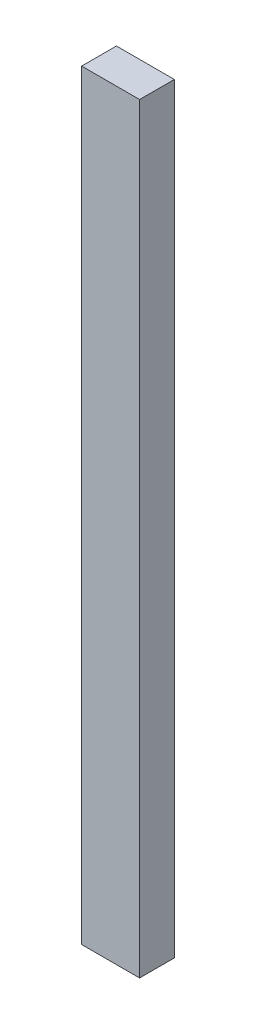
from build123d import *

# Parameters (mm, degrees)
SKETCH1_W           = 30
SKETCH1_H           = 394
BOSS_EXTRUDE1_DEPTH = 18


with BuildPart() as part:
    # Sketch1 → Boss-Extrude1 (new body)
    with BuildSketch(Plane.XY):
        Rectangle(SKETCH1_W, SKETCH1_H)
    extrude(amount=BOSS_EXTRUDE1_DEPTH)


solid = part.part
